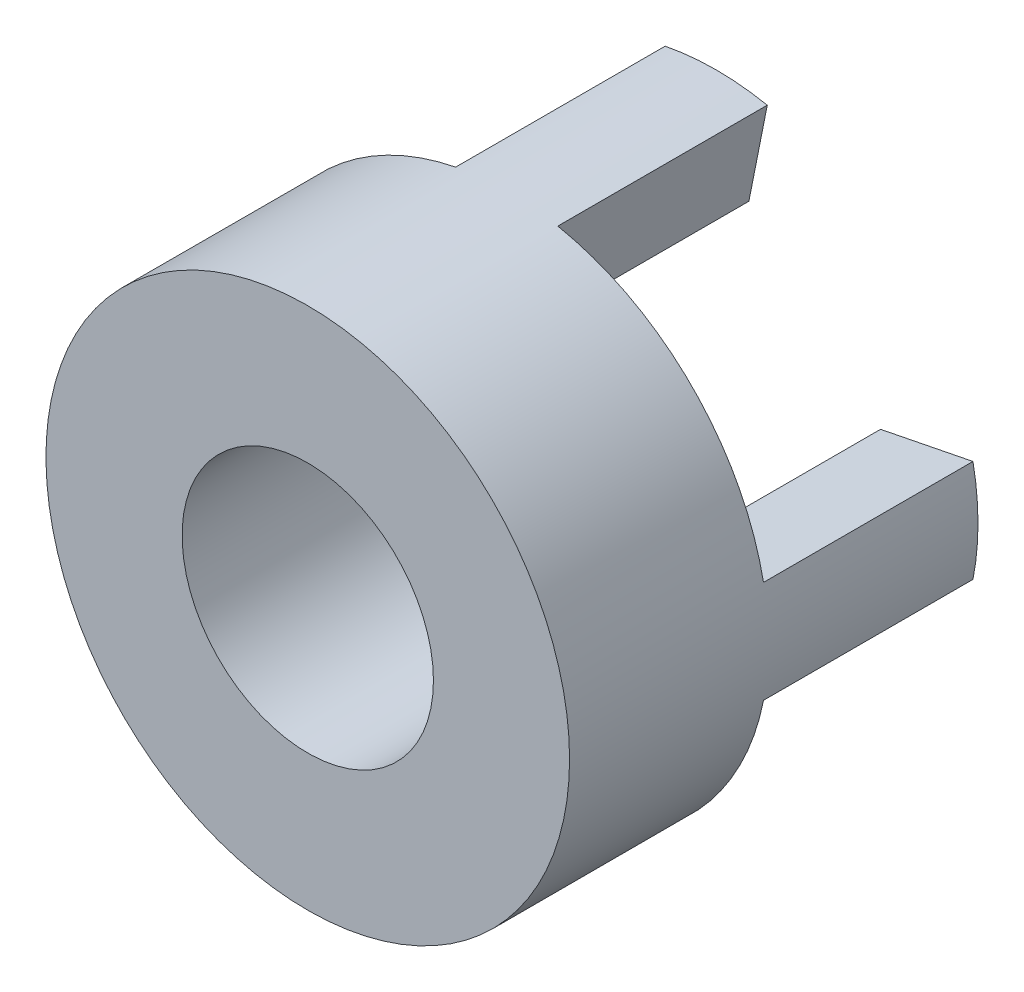
from build123d import *

# Parameters (mm, degrees)
SKETCH_1_R      = 12.5
SKETCH_1_R_2    = 6
EXTRUDE_1_DEPTH = 9.5
EXTRUDE_2_DEPTH = 10


with BuildPart() as part:
    # 草图1 → 凸台-拉伸1 (new body)
    with BuildSketch(Plane.XY):
        Circle(SKETCH_1_R)
        Circle(SKETCH_1_R_2, mode=Mode.SUBTRACT)
    extrude(amount=EXTRUDE_1_DEPTH)

    # 草图2 → 凸台-拉伸2 (add)
    with BuildSketch(Plane(origin=(0, 0, 0), x_dir=(-1, 0, 0), z_dir=(0, 0, -1))):
        with BuildLine():
            Line((7.846282243, -1.560722576), (12.259816005, -2.438629025))
            ThreePointArc((12.259816005, -2.438629025), (12.5, 0), (12.259816005, 2.438629025))
            Line((12.259816005, 2.438629025), (7.846282243, 1.560722576))
            ThreePointArc((7.846282243, 1.560722576), (8, 0), (7.846282243, -1.560722576))
        make_face()
        with BuildLine():
            Line((1.560722576, 7.846282243), (2.438629025, 12.259816005))
            ThreePointArc((2.438629025, 12.259816005), (0, 12.5), (-2.438629025, 12.259816005))
            Line((-2.438629025, 12.259816005), (-1.560722576, 7.846282243))
            ThreePointArc((-1.560722576, 7.846282243), (0, 8), (1.560722576, 7.846282243))
        make_face()
        with BuildLine():
            Line((-1.560722576, -7.846282243), (-2.438629025, -12.259816005))
            ThreePointArc((-2.438629025, -12.259816005), (0, -12.5), (2.438629025, -12.259816005))
            Line((2.438629025, -12.259816005), (1.560722576, -7.846282243))
            ThreePointArc((1.560722576, -7.846282243), (0, -8), (-1.560722576, -7.846282243))
        make_face()
        with BuildLine():
            Line((-7.846282243, 1.560722576), (-12.259816005, 2.438629025))
            ThreePointArc((-12.259816005, 2.438629025), (-12.5, 0), (-12.259816005, -2.438629025))
            Line((-12.259816005, -2.438629025), (-7.846282243, -1.560722576))
            ThreePointArc((-7.846282243, -1.560722576), (-8, 0), (-7.846282243, 1.560722576))
        make_face()
    extrude(amount=EXTRUDE_2_DEPTH)


solid = part.part
